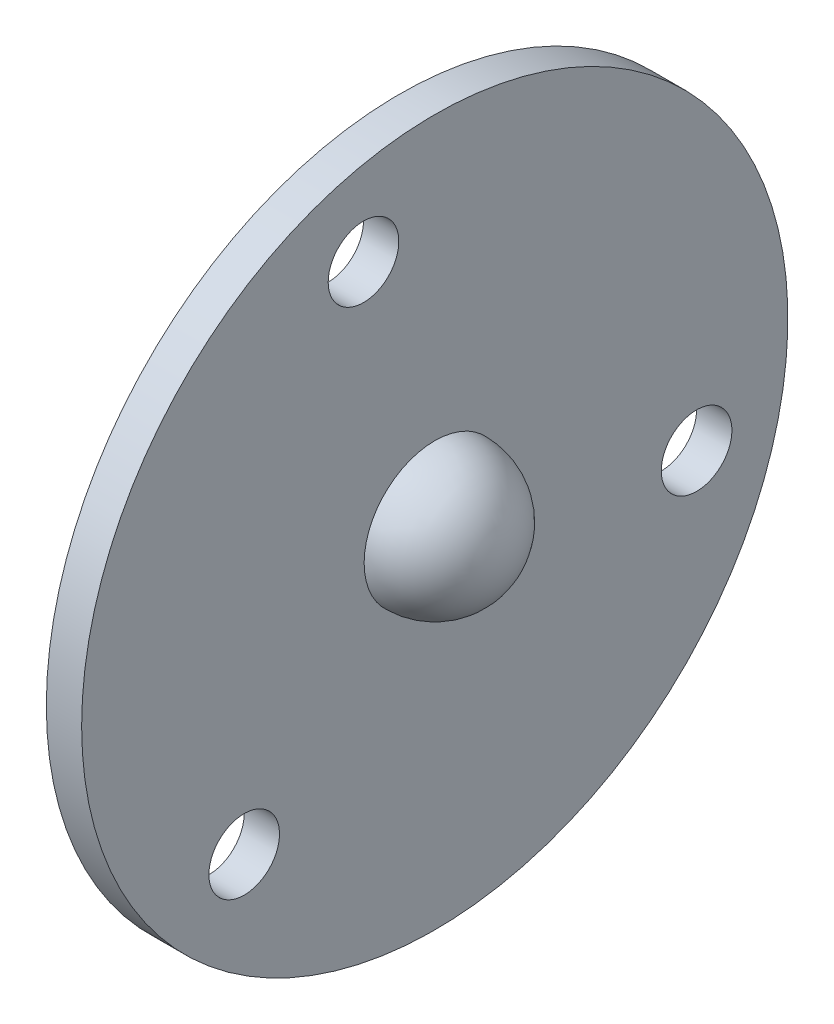
from build123d import *

# Parameters (mm, degrees)
ESQUISSE3_R                  = 3
ENL_V_MAT_EXTRU_1_DEPTH      = 10
R_P_TITION_CIRCULAIRE1_COUNT = 3


with BuildPart() as part:
    # Esquisse2 → Révolution1 (revolve)
    with BuildSketch(Plane(origin=(0, 0, 0), x_dir=(1, 0, 0), z_dir=(0, 1, 0))):
        with BuildLine():
            Line((-24.196325381, 6), (-24.196325381, 30))
            Line((-24.196325381, 30), (-27.196325381, 30))
            Line((-27.196325381, 30), (-27.196325381, 11))
            ThreePointArc((-27.196325381, 11), (-34.974499974, 7.778174593), (-38.196325381, 0))
            Line((-38.196325381, 0), (-18.196325381, 0))
            ThreePointArc((-18.196325381, 0), (-19.953684694, 4.242640687), (-24.196325381, 6))
        make_face()
    revolve(axis=Axis((-57.66931647, 0, 0), (1, 0, 0)))

    # Esquisse3 → Enlèv. mat.-Extru.1 (cut)
    with BuildSketch(Plane.ZY.offset(27.196325381)):
        with Locations((-22.243253738, -5.851295854)):
            Circle(ESQUISSE3_R)
    enl_v_mat_extru_1 = extrude(amount=-ENL_V_MAT_EXTRU_1_DEPTH, mode=Mode.SUBTRACT)

    # Répétition circulaire1: Enlèv. mat.-Extru.1 ×3 about axis
    r_p_tition_circulaire1_axis = Axis((0, 0, 0), (1, 0, 0))
    for i in range(1, R_P_TITION_CIRCULAIRE1_COUNT):
        add(enl_v_mat_extru_1.rotate(r_p_tition_circulaire1_axis, i * 360 / R_P_TITION_CIRCULAIRE1_COUNT), mode=Mode.SUBTRACT)


solid = part.part
